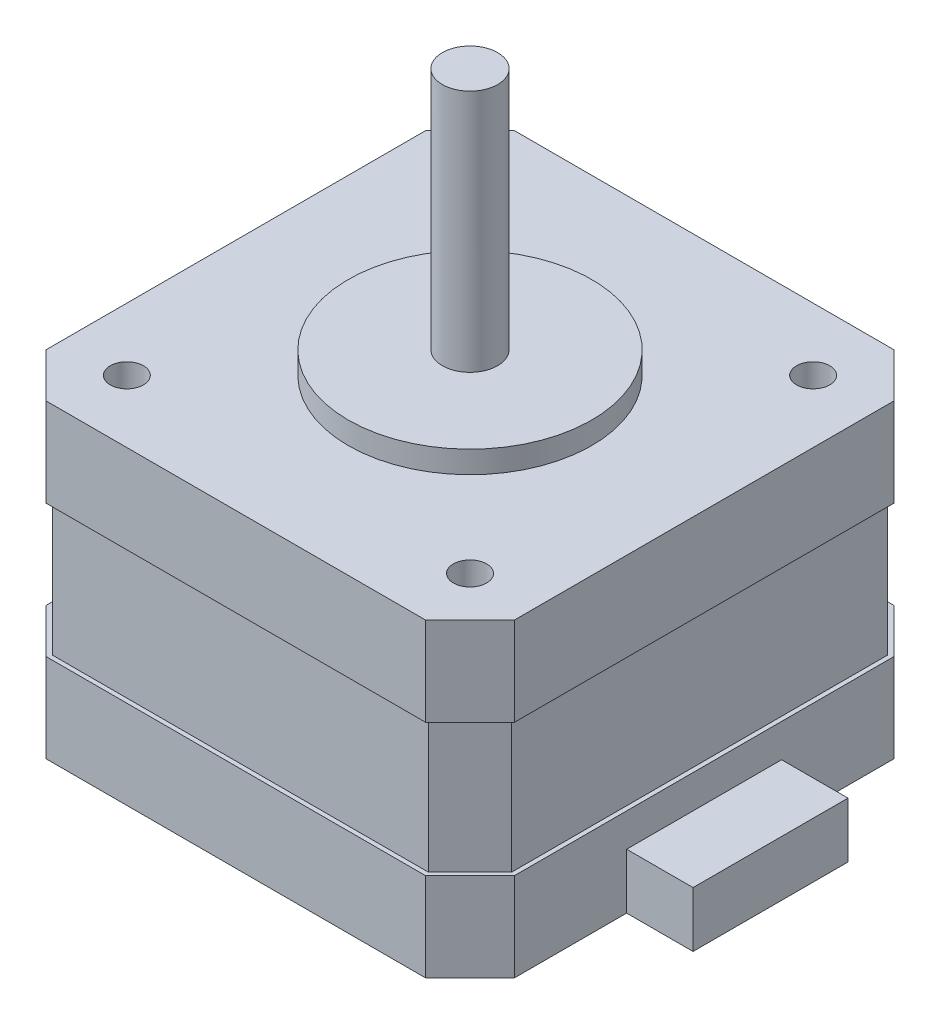
from build123d import *

# Parameters (mm, degrees)
SKETCH_2_W          = 42.3
SKETCH_2_H          = 42.3
EXTRUDE_1_DEPTH     = 28
SKETCH_3_R          = 11
EXTRUDE_2_DEPTH     = 2
EXTRUDE_START       = -2
SKETCH_4_R          = 2.5
EXTRUDE_3_DEPTH     = 24
SKETCH_5_R          = 1.5
CUT_EXTRUDE_1_DEPTH = 4.5
CHAMFER_1_SIZE      = 4
CUT_EXTRUDE_START   = -8
SKETCH_6_OUTSIDE_W  = 60.152
SKETCH_6_OUTSIDE_H  = 60.152
CUT_EXTRUDE_2_DEPTH = 12
SKETCH_7_R          = 2.5
EXTRUDE_4_DEPTH     = 2
CHAMFER_2_SIZE      = 1
SKETCH_8_W          = 14
SKETCH_8_H          = 5
EXTRUDE_5_DEPTH     = 6


with BuildPart() as part:
    # Эскиз2 → Бобышка-Вытянуть1 (new body)
    with BuildSketch(Plane(origin=(0, 0, 0), x_dir=(1, 0, 0), z_dir=(0, 1, 0))):
        Rectangle(SKETCH_2_W, SKETCH_2_H)
    extrude(amount=EXTRUDE_1_DEPTH)

    # Эскиз3 → Бобышка-Вытянуть2 (add)
    with BuildSketch(Plane(origin=(0, 28, 0), x_dir=(1, 0, 0), z_dir=(0, 1, 0))):
        Circle(SKETCH_3_R)
    extrude(amount=EXTRUDE_2_DEPTH)

    # Эскиз4 → Бобышка-Вытянуть3 (add)
    with BuildSketch(Plane(origin=(0, 30, 0), x_dir=(1, 0, 0), z_dir=(0, 1, 0)).offset(EXTRUDE_START)):
        Circle(SKETCH_4_R)
    extrude(amount=EXTRUDE_3_DEPTH)

    # Эскиз5 → Вырез-Вытянуть1 (cut)
    with BuildSketch(Plane(origin=(0, 28, 0), x_dir=(1, 0, 0), z_dir=(0, 1, 0))):
        with Locations((-15.5, 15.5)):
            Circle(SKETCH_5_R)
        with Locations((15.5, 15.5)):
            Circle(SKETCH_5_R)
        with Locations((15.5, -15.5)):
            Circle(SKETCH_5_R)
        with Locations((-15.5, -15.5)):
            Circle(SKETCH_5_R)
    extrude(amount=-CUT_EXTRUDE_1_DEPTH, mode=Mode.SUBTRACT)

    # Фаска1
    chamfer_1_edges = [part.edges().sort_by_distance(p)[0] for p in [
        (21.15, 14, 21.15),
        (-21.15, 14, 21.15),
        (-21.15, 14, -21.15),
        (21.15, 14, -21.15),
    ]]
    chamfer(chamfer_1_edges, length=CHAMFER_1_SIZE)

    # Эскиз6 outside → Вырез-Вытянуть2 (cut)
    with BuildSketch(Plane(origin=(0, 28, 0), x_dir=(1, 0, 0), z_dir=(0, 1, 0)).offset(CUT_EXTRUDE_START)):
        Rectangle(SKETCH_6_OUTSIDE_W, SKETCH_6_OUTSIDE_H)
        Polygon((-20.75, 16.984314575), (-20.75, -16.984314575), (-16.984314575, -20.75), (16.984314575, -20.75), (20.75, -16.984314575), (20.75, 16.984314575), (16.984314575, 20.75), (-16.984314575, 20.75), align=None, mode=Mode.SUBTRACT)
    extrude(amount=-CUT_EXTRUDE_2_DEPTH, mode=Mode.SUBTRACT)

    # Эскиз7 → Бобышка-Вытянуть4 (add)
    with BuildSketch(Plane.XZ):
        with Locations((-15.5, -15.5)):
            Circle(SKETCH_7_R)
        with Locations((15.5, -15.5)):
            Circle(SKETCH_7_R)
        with Locations((15.5, 15.5)):
            Circle(SKETCH_7_R)
        with Locations((-15.5, 15.5)):
            Circle(SKETCH_7_R)
    extrude(amount=EXTRUDE_4_DEPTH)

    # Фаска2
    chamfer_2_edges = [part.edges().sort_by_distance(p)[0] for p in [
        (-18, -2, -15.5),
        (13, -2, -15.5),
        (13, -2, 15.5),
        (-18, -2, 15.5),
    ]]
    chamfer(chamfer_2_edges, length=CHAMFER_2_SIZE)

    # Эскиз8 → Бобышка-Вытянуть5 (add)
    with BuildSketch(Plane(origin=(21.15, 0, 0), x_dir=(0, 0, -1), z_dir=(1, 0, 0))):
        with Locations((0, 2.5)):
            Rectangle(SKETCH_8_W, SKETCH_8_H)
    extrude(amount=EXTRUDE_5_DEPTH)


solid = part.part
